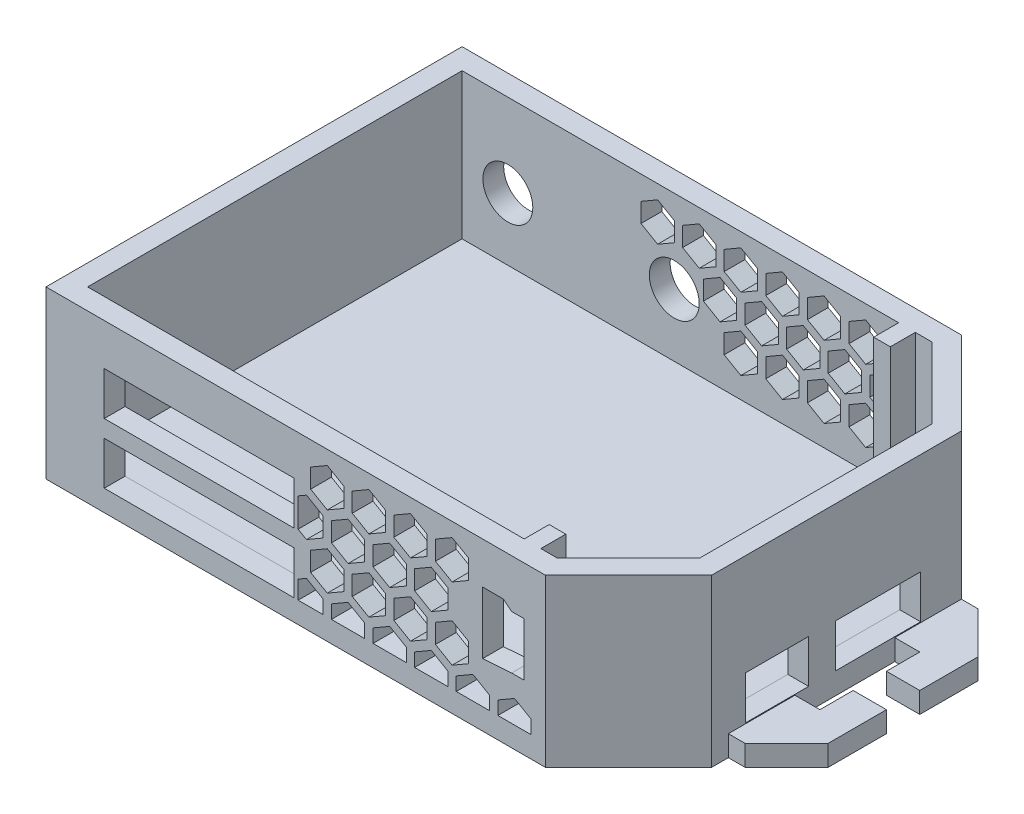
from build123d import *

# Parameters (mm, degrees)
SKETCH1_W            = 70
SKETCH1_H            = 50
BOSS_EXTRUDE1_DEPTH  = 20
CHAMFER2_SIZE        = 10
SHELL3_T             = -2.5
SKETCH2_R            = 3
CUT_EXTRUDE1_DEPTH   = 20
SKETCH3_W            = 2
SKETCH3_H            = 17.5
BOSS_EXTRUDE2_DEPTH  = 3
SKETCH4_W            = 2
SKETCH4_H            = 4
BOSS_EXTRUDE3_DEPTH  = 3
SKETCH6_W            = 2
SKETCH6_H            = 4
BOSS_EXTRUDE4_DEPTH  = 3
CUT_EXTRUDE4_DEPTH   = 3
SKETCH11_W           = 22.8
SKETCH11_H           = 5.2
CUT_EXTRUDE5_DEPTH   = 4
SKETCH12_W           = 7.6
SKETCH12_H           = 5.2
CUT_EXTRUDE6_DEPTH   = 4
SKETCH13_W           = 10.2
SKETCH13_H           = 5.2
CUT_EXTRUDE7_DEPTH   = 4
SKETCH18_W           = 8
SKETCH18_H           = 2.5
BOSS_EXTRUDE5_DEPTH  = 7
SKETCH19_W           = 4
SKETCH19_H           = 2.5
BOSS_EXTRUDE6_DEPTH  = 4
SKETCH20_W           = 4
SKETCH20_H           = 2.5
BOSS_EXTRUDE7_DEPTH  = 4
CHAMFER3_SIZE        = 5
SKETCH23_W           = 8
SKETCH23_H           = 2.5
BOSS_EXTRUDE8_DEPTH  = 7
SKETCH24_W           = 4
SKETCH24_H           = 2.5
BOSS_EXTRUDE10_DEPTH = 4
SKETCH25_W           = 4
SKETCH25_H           = 2.5
BOSS_EXTRUDE11_DEPTH = 4
CHAMFER4_SIZE        = 5
SKETCH26_R           = 3
CUT_EXTRUDE10_DEPTH  = 4
CUT_EXTRUDE11_DEPTH  = 4
CUT_EXTRUDE13_DEPTH  = 4


with BuildPart() as part:
    # Sketch1 → Boss-Extrude1 (new body)
    with BuildSketch(Plane(origin=(0, 0, 0), x_dir=(1, 0, 0), z_dir=(0, 1, 0))):
        Rectangle(SKETCH1_W, SKETCH1_H)
    extrude(amount=BOSS_EXTRUDE1_DEPTH)

    # Chamfer2
    chamfer2_edges = [part.edges().sort_by_distance(p)[0] for p in [
        (35, 10, 25),
        (35, 10, -25),
    ]]
    chamfer(chamfer2_edges, length=CHAMFER2_SIZE)

    # Shell3
    shell3_openings = [part.faces().sort_by_distance(p)[0] for p in [
        (8.333333333, 20, 0),
    ]]
    offset(amount=SHELL3_T, openings=shell3_openings, kind=Kind.INTERSECTION)

    # Sketch2 → Cut-Extrude1 (cut)
    with BuildSketch(Plane(origin=(0, 0, -25), x_dir=(-1, 0, 0), z_dir=(0, 0, -1))):
        with Locations((27, 10)):
            Circle(SKETCH2_R)
    extrude(amount=-CUT_EXTRUDE1_DEPTH, mode=Mode.SUBTRACT)

    # Sketch3 → Boss-Extrude2 (add)
    with BuildSketch(Plane.XY.offset(-22.5)):
        with Locations((20.964466094, 11.25)):
            Rectangle(SKETCH3_W, SKETCH3_H)
    extrude(amount=BOSS_EXTRUDE2_DEPTH)

    # Sketch4 → Boss-Extrude3 (add)
    with BuildSketch(Plane(origin=(0, 0, 22.5), x_dir=(-1, 0, 0), z_dir=(0, 0, -1))):
        with Locations((-20.964466094, 4.5)):
            Rectangle(SKETCH4_W, SKETCH4_H)
    extrude(amount=BOSS_EXTRUDE3_DEPTH)

    # Sketch6 → Boss-Extrude4 (add)
    with BuildSketch(Plane(origin=(0, 0, 22.5), x_dir=(-1, 0, 0), z_dir=(0, 0, -1))):
        with Locations((-20.964466094, 18)):
            Rectangle(SKETCH6_W, SKETCH6_H)
    extrude(amount=BOSS_EXTRUDE4_DEPTH)

    # Sketch10 → Cut-Extrude4 (cut)
    with BuildSketch(Plane(origin=(0, 0, 22.5), x_dir=(-1, 0, 0), z_dir=(0, 0, -1))):
        Polygon((-17.464466094, 15), (-19.964466094, 15), (-20.964466094, 14.2), (-22.464466094, 14.2), (-22.464466094, 7.8), (-20.964466094, 7.8), (-17.464466094, 7.545454545), align=None)
    extrude(amount=-CUT_EXTRUDE4_DEPTH, mode=Mode.SUBTRACT)

    # Sketch11 → Cut-Extrude5 (cut)
    with BuildSketch(Plane.XY.offset(25)):
        with Locations((-16.6, 12.4)):
            Rectangle(SKETCH11_W, SKETCH11_H)
        with Locations((-16.6, 5.146)):
            Rectangle(SKETCH11_W, SKETCH11_H)
    extrude(amount=-CUT_EXTRUDE5_DEPTH, mode=Mode.SUBTRACT)

    # Sketch12 → Cut-Extrude6 (cut)
    with BuildSketch(Plane(origin=(35, 0, 0), x_dir=(0, 0, -1), z_dir=(1, 0, 0))):
        with Locations((-7.152128029, 5.2)):
            Rectangle(SKETCH12_W, SKETCH12_H)
    extrude(amount=-CUT_EXTRUDE6_DEPTH, mode=Mode.SUBTRACT)

    # Sketch13 → Cut-Extrude7 (cut)
    with BuildSketch(Plane(origin=(35, 0, 0), x_dir=(0, 0, -1), z_dir=(1, 0, 0))):
        with Locations((4.997871971, 5.2)):
            Rectangle(SKETCH13_W, SKETCH13_H)
    extrude(amount=-CUT_EXTRUDE7_DEPTH, mode=Mode.SUBTRACT)

    # Sketch18 → Boss-Extrude5 (add)
    with BuildSketch(Plane.ZY.offset(35)):
        with Locations((-11, 1.25)):
            Rectangle(SKETCH18_W, SKETCH18_H)
        with Locations((9, 1.25)):
            Rectangle(SKETCH18_W, SKETCH18_H)
    extrude(amount=BOSS_EXTRUDE5_DEPTH)

    # Sketch19 → Boss-Extrude6 (add)
    with BuildSketch(Plane.XY.offset(-7)):
        with Locations((-40, 1.25)):
            Rectangle(SKETCH19_W, SKETCH19_H)
    extrude(amount=BOSS_EXTRUDE6_DEPTH)

    # Sketch20 → Boss-Extrude7 (add)
    with BuildSketch(Plane(origin=(0, 0, 5), x_dir=(-1, 0, 0), z_dir=(0, 0, -1))):
        with Locations((40, 1.25)):
            Rectangle(SKETCH20_W, SKETCH20_H)
    extrude(amount=BOSS_EXTRUDE7_DEPTH)

    # Chamfer3
    chamfer3_edges = [part.edges().sort_by_distance(p)[0] for p in [
        (-42, 1.25, -15),
        (-42, 1.25, 13),
    ]]
    chamfer(chamfer3_edges, length=CHAMFER3_SIZE)

    # Sketch23 → Boss-Extrude8 (add)
    with BuildSketch(Plane(origin=(35, 0, 0), x_dir=(0, 0, -1), z_dir=(1, 0, 0))):
        with Locations((-9, 1.25)):
            Rectangle(SKETCH23_W, SKETCH23_H)
        with Locations((11, 1.25)):
            Rectangle(SKETCH23_W, SKETCH23_H)
    extrude(amount=BOSS_EXTRUDE8_DEPTH)

    # Sketch24 → Boss-Extrude10 (add)
    with BuildSketch(Plane.XY.offset(-7)):
        with Locations((40, 1.25)):
            Rectangle(SKETCH24_W, SKETCH24_H)
    extrude(amount=BOSS_EXTRUDE10_DEPTH)

    # Sketch25 → Boss-Extrude11 (add)
    with BuildSketch(Plane(origin=(0, 0, 5), x_dir=(-1, 0, 0), z_dir=(0, 0, -1))):
        with Locations((-40, 1.25)):
            Rectangle(SKETCH25_W, SKETCH25_H)
    extrude(amount=BOSS_EXTRUDE11_DEPTH)

    # Chamfer4
    chamfer4_edges = [part.edges().sort_by_distance(p)[0] for p in [
        (42, 1.25, 13),
        (42, 1.25, -15),
    ]]
    chamfer(chamfer4_edges, length=CHAMFER4_SIZE)

    # Sketch26 → Cut-Extrude10 (cut)
    with BuildSketch(Plane(origin=(0, 0, -25), x_dir=(-1, 0, 0), z_dir=(0, 0, -1))):
        with Locations((7, 10)):
            Circle(SKETCH26_R)
    extrude(amount=-CUT_EXTRUDE10_DEPTH, mode=Mode.SUBTRACT)

    # Sketch27 → Cut-Extrude11 (cut)
    with BuildSketch(Plane.XY.offset(25)):
        Polygon((-4.7, 2.546), (-1.7, 2.546), (-1.7, 4.164319482), (-3.7, 5.31902002), (-4.7, 4.741669751), align=None)
        Polygon((-0.7, 2.546), (3.3, 2.546), (3.3, 4.164319482), (1.3, 5.31902002), (-0.7, 4.164319482), align=None)
        Polygon((-3.2, 6.185045424), (-1.2, 5.030344885), (0.8, 6.185045424), (0.8, 8.494446501), (-1.2, 9.649147039), (-3.2, 8.494446501), align=None)
        Polygon((1.8, 8.494446501), (1.8, 6.185045424), (3.8, 5.030344885), (5.8, 6.185045424), (5.8, 8.494446501), (3.8, 9.649147039), align=None)
        Polygon((8.3, 4.164319482), (6.3, 5.31902002), (4.3, 4.164319482), (4.3, 2.546), (8.3, 2.546), align=None)
        Polygon((9.3, 4.164319482), (9.3, 2.546), (13.3, 2.546), (13.3, 4.164319482), (11.3, 5.31902002), align=None)
        Polygon((10.8, 6.185045424), (10.8, 8.494446501), (8.8, 9.649147039), (6.8, 8.494446501), (6.8, 6.185045424), (8.8, 5.030344885), align=None)
        Polygon((15.8, 6.185045424), (15.8, 8.494446501), (13.8, 9.649147039), (11.8, 8.494446501), (11.8, 6.185045424), (13.8, 5.030344885), align=None)
        Polygon((14.3, 4.164319482), (14.3, 2.546), (18.3, 2.546), (18.3, 4.164319482), (16.3, 5.31902002), align=None)
        Polygon((19.3, 4.164319482), (19.3, 2.546), (23.3, 2.546), (23.3, 4.164319482), (21.3, 5.31902002), align=None)
        Polygon((13.3, 10.515172443), (13.3, 12.824573519), (11.3, 13.979274058), (9.3, 12.824573519), (9.3, 10.515172443), (11.3, 9.360471904), align=None)
        Polygon((11.8, 17.154700538), (11.8, 14.845299462), (13.8, 13.690598923), (15.8, 14.845299462), (15.8, 17.154700538), (13.8, 18.309401077), align=None)
        Polygon((6.8, 17.154700538), (6.8, 14.845299462), (8.8, 13.690598923), (10.8, 14.845299462), (10.8, 17.154700538), (8.8, 18.309401077), align=None)
        Polygon((8.3, 10.515172443), (8.3, 12.824573519), (6.3, 13.979274058), (4.3, 12.824573519), (4.3, 10.515172443), (6.3, 9.360471904), align=None)
        Polygon((1.8, 17.154700538), (1.8, 14.845299462), (3.8, 13.690598923), (5.8, 14.845299462), (5.8, 17.154700538), (3.8, 18.309401077), align=None)
        Polygon((-0.7, 12.824573519), (-0.7, 10.515172443), (1.3, 9.360471904), (3.3, 10.515172443), (3.3, 12.824573519), (1.3, 13.979274058), align=None)
        Polygon((-4.7, 13.401923789), (-4.7, 9.937822174), (-3.7, 9.360471904), (-1.7, 10.515172443), (-1.7, 12.824573519), (-3.7, 13.979274058), align=None)
        Polygon((-1.2, 13.690598923), (0.8, 14.845299462), (0.8, 17.154700538), (-1.2, 18.309401077), (-3.2, 17.154700538), (-3.2, 14.845299462), align=None)
    extrude(amount=-CUT_EXTRUDE11_DEPTH, mode=Mode.SUBTRACT)

    # Sketch33 → Cut-Extrude13 (cut)
    with BuildSketch(Plane(origin=(0, 0, -25), x_dir=(-1, 0, 0), z_dir=(0, 0, -1))):
        Polygon((-0.5, 12.824573519), (-0.5, 10.515172443), (1.5, 9.360471904), (3.5, 10.515172443), (3.5, 12.824573519), (1.5, 13.979274058), align=None)
        Polygon((2, 17.154700538), (2, 14.845299462), (4, 13.690598923), (6, 14.845299462), (6, 17.154700538), (4, 18.309401077), align=None)
        Polygon((7, 17.154700538), (7, 14.845299462), (9, 13.690598923), (11, 14.845299462), (11, 17.154700538), (9, 18.309401077), align=None)
        Polygon((-1, 13.690598923), (1, 14.845299462), (1, 17.154700538), (-1, 18.309401077), (-3, 17.154700538), (-3, 14.845299462), align=None)
        Polygon((-3.5, 9.360471904), (-1.5, 10.515172443), (-1.5, 12.824573519), (-3.5, 13.979274058), (-5.5, 12.824573519), (-5.5, 10.515172443), align=None)
        Polygon((-1, 5.030344885), (1, 6.185045424), (1, 8.494446501), (-1, 9.649147039), (-3, 8.494446501), (-3, 6.185045424), align=None)
        Polygon((-8, 8.494446501), (-8, 6.185045424), (-6, 5.030344885), (-4, 6.185045424), (-4, 8.494446501), (-6, 9.649147039), align=None)
        Polygon((-10.5, 12.824573519), (-10.5, 10.515172443), (-8.5, 9.360471904), (-6.5, 10.515172443), (-6.5, 12.824573519), (-8.5, 13.979274058), align=None)
        Polygon((-8, 17.154700538), (-8, 14.845299462), (-6, 13.690598923), (-4, 14.845299462), (-4, 17.154700538), (-6, 18.309401077), align=None)
        Polygon((-13, 17.154700538), (-13, 14.845299462), (-11, 13.690598923), (-9, 14.845299462), (-9, 17.154700538), (-11, 18.309401077), align=None)
        Polygon((-15.5, 12.824573519), (-15.5, 10.515172443), (-13.5, 9.360471904), (-11.5, 10.515172443), (-11.5, 12.824573519), (-13.5, 13.979274058), align=None)
        Polygon((-18, 17.154700538), (-18, 14.845299462), (-16, 13.690598923), (-14, 14.845299462), (-14, 17.154700538), (-16, 18.309401077), align=None)
        Polygon((-20.5, 12.824573519), (-20.5, 10.515172443), (-18.5, 9.360471904), (-16.5, 10.515172443), (-16.5, 12.824573519), (-18.5, 13.979274058), align=None)
        Polygon((-18, 8.494446501), (-18, 6.185045424), (-16, 5.030344885), (-14, 6.185045424), (-14, 8.494446501), (-16, 9.649147039), align=None)
        Polygon((-13, 8.494446501), (-13, 6.185045424), (-11, 5.030344885), (-9, 6.185045424), (-9, 8.494446501), (-11, 9.649147039), align=None)
    extrude(amount=-CUT_EXTRUDE13_DEPTH, mode=Mode.SUBTRACT)


solid = part.part
